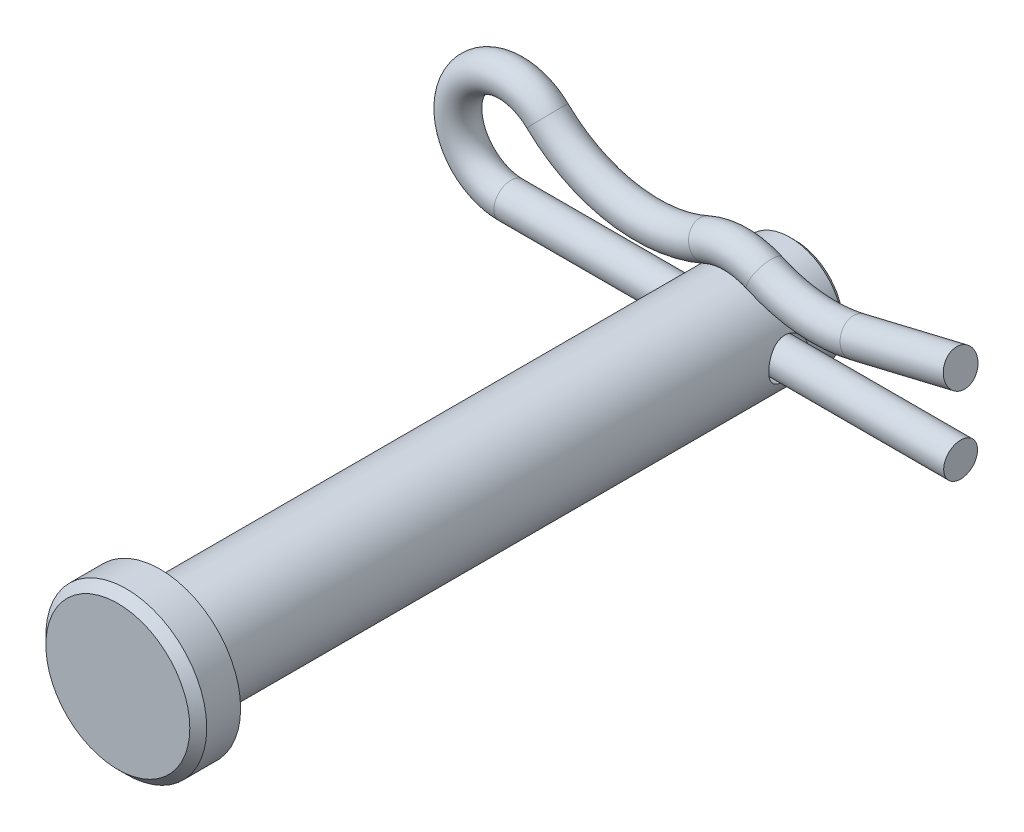
from build123d import *

# Parameters (mm, degrees)
SKETCH1_R           = 3.175
EXTRUDE1_DEPTH      = 19.05
SKETCH2_R           = 4.826
EXTRUDE2_DEPTH      = 2.54
CHAMFER1_SIZE       = 0.508
SKETCH3_R           = 1.190625
EXTRUDE3_DEPTH      = 5.826
EXTRUDE3_DEPTH_BACK = 5.826
CHAMFER2_SIZE       = 0.3175
SKETCH7_R           = 1.016


with BuildPart() as part:
    # Sketch1 → Extrude1 (new body, symmetric)
    with BuildSketch(Plane.XY):
        Circle(SKETCH1_R)
    extrude(amount=EXTRUDE1_DEPTH, both=True)

    # Sketch2 → Extrude2 (add)
    with BuildSketch(Plane.XY.offset(19.05)):
        Circle(SKETCH2_R)
    extrude(amount=EXTRUDE2_DEPTH)

    # Chamfer1
    chamfer1_edges = [part.edges().sort_by_distance(p)[0] for p in [
        (-4.826, 0, 21.59),
    ]]
    chamfer(chamfer1_edges, length=CHAMFER1_SIZE)

    # Sketch3 → Extrude3 (cut, two sides)
    with BuildSketch(Plane(origin=(0, 0, 0), x_dir=(0, 0, -1), z_dir=(1, 0, 0))) as extrude3_sk:
        with Locations((15.478125, 0)):
            Circle(SKETCH3_R)
    extrude(amount=EXTRUDE3_DEPTH, mode=Mode.SUBTRACT)
    extrude(extrude3_sk.sketch, amount=-EXTRUDE3_DEPTH_BACK, mode=Mode.SUBTRACT)

    # Chamfer2
    chamfer2_edges = [part.edges().sort_by_distance(p)[0] for p in [
        (-3.175, 0, -19.05),
    ]]
    chamfer(chamfer2_edges, length=CHAMFER2_SIZE)


with BuildPart() as body_2:
    # Sweep1: sweep along a path in Sketch6
    with BuildLine(Plane.XY.offset(-15.478125)) as sweep1_path:
        Line((13.49375, 0), (-13.49375, 0))
        ThreePointArc((-13.49375, 0), (-16.438801729, 4.361294783), (-11.292994408, 5.463514764))
        ThreePointArc((-11.292994408, 5.463514764), (-6.763179694, 3.173261299), (-1.728419774, 3.817989796))
        ThreePointArc((-1.728419774, 3.817989796), (0, 4.191), (1.728419774, 3.817989796))
        ThreePointArc((1.728419774, 3.817989796), (4.472851559, 3.087280395), (7.306026778, 3.28466386))
        Line((7.306026778, 3.28466386), (13.49375, 4.7625))
    # Sketch7 → Sweep1 (sweep)
    with BuildSketch(Plane(origin=(13.49375, 0, -15.478125), x_dir=(0, 0, 1), z_dir=(-1, 0, 0))):
        Circle(SKETCH7_R)
    sweep(path=sweep1_path.line)


solid = Compound([part.part, body_2.part])
